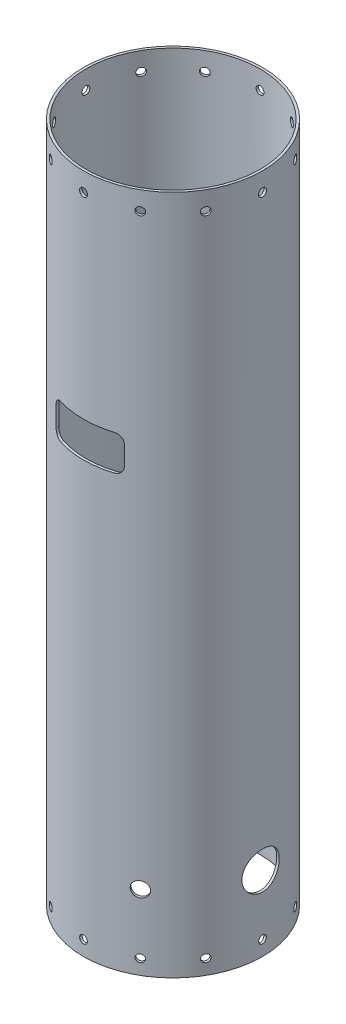
from build123d import *

# Parameters (mm, degrees)
SKETCH_BODY_TUBE_W           = 2.0828
SKETCH_BODY_TUBE_H           = 579.0946
F_1_4_CLEARANCE_HOLE1_REACH  = 605.641
F_1_4_CLEARANCE_HOLE1_BORE_R = 3.3782
CIRPATTERN1_COUNT            = 12
F_1_4_CLEARANCE_HOLE2_REACH  = 593.469
F_1_4_CLEARANCE_HOLE2_BORE_R = 3.2639
CIRPATTERN2_COUNT            = 12
SKETCH5_R                    = 4
SCREW_SWITCH_HOLES_DEPTH     = 590.036022579
SKETCH7_R                    = 12.7
UMBILICAL_HOLE_DEPTH         = 590.036022579
SKETCH8_R                    = 15.875
CONDUIT_HOLE_DEPTH           = 590.036022579
CUT_EXTRUDE5_DEPTH           = 590.036022579
CUT_EXTRUDE7_REACH           = 609.152
CUT_EXTRUDE7_END_RADIUS      = 74.1172
SKETCH12_R                   = 6.35


with BuildPart() as part:
    # Sketch - Body Tube → Revolve - Body Tube (revolve)
    with BuildSketch(Plane.XY, mode=Mode.PRIVATE) as revolve_body_tube_sk:
        with Locations((-75.1586, 289.5473)):
            Rectangle(SKETCH_BODY_TUBE_W, SKETCH_BODY_TUBE_H)
    revolve(revolve_body_tube_sk.sketch.rotate(Axis((0, 0, 0), (0, 1, 0)), 270), axis=Axis((0, 0, 0), (0, 1, 0)))

    # 1_4 Clearance Hole1 bore → 1_4 Clearance Hole1 (cut, up to next)
    with BuildSketch(Plane.XY.offset(76.2), mode=Mode.PRIVATE) as f_1_4_clearance_hole1_sk1:
        with Locations((0, 563.245)):
            Circle(F_1_4_CLEARANCE_HOLE1_BORE_R)
    f_1_4_clearance_hole1_tool1 = extrude(f_1_4_clearance_hole1_sk1.sketch, amount=-F_1_4_CLEARANCE_HOLE1_REACH, mode=Mode.PRIVATE) & part.part
    f_1_4_clearance_hole1 = f_1_4_clearance_hole1_tool1.solids().sort_by_distance((0, 563.245, 76.2))[0]
    add(f_1_4_clearance_hole1, mode=Mode.SUBTRACT)

    # CirPattern1: 1_4 Clearance Hole1 ×12 about axis
    cirpattern1_axis = Axis((0, 0, 0), (0, -1, 0))
    for i in range(1, CIRPATTERN1_COUNT):
        add(f_1_4_clearance_hole1.rotate(cirpattern1_axis, i * 360 / CIRPATTERN1_COUNT), mode=Mode.SUBTRACT)

    # 1_4 Clearance Hole2 bore (on position points) → 1_4 Clearance Hole2 (cut, up to next)
    with BuildSketch(Plane(origin=(0, 12.7, 76.2), x_dir=(1, 0, 0), z_dir=(0, 0, 1)), mode=Mode.PRIVATE) as f_1_4_clearance_hole2_sk1:
        Circle(F_1_4_CLEARANCE_HOLE2_BORE_R)
    f_1_4_clearance_hole2_tool1 = extrude(f_1_4_clearance_hole2_sk1.sketch, amount=-F_1_4_CLEARANCE_HOLE2_REACH, mode=Mode.PRIVATE) & part.part
    f_1_4_clearance_hole2 = f_1_4_clearance_hole2_tool1.solids().sort_by_distance((0, 12.7, 76.2))[0]
    add(f_1_4_clearance_hole2, mode=Mode.SUBTRACT)

    # CirPattern2: 1_4 Clearance Hole2 ×12 about axis
    cirpattern2_axis = Axis((0, 55, 0), (0, -1, 0))
    for i in range(1, CIRPATTERN2_COUNT):
        add(f_1_4_clearance_hole2.rotate(cirpattern2_axis, i * 360 / CIRPATTERN2_COUNT), mode=Mode.SUBTRACT)

    # Sketch5 → Screw Switch Holes (cut, through all)
    with BuildSketch(Plane.XY):
        with Locations((-17.3115, 371.770469026)):
            Circle(SKETCH5_R)
        with Locations((-5.7705, 371.770469026)):
            Circle(SKETCH5_R)
        with Locations((5.7705, 371.770469026)):
            Circle(SKETCH5_R)
        with Locations((17.3115, 371.770469026)):
            Circle(SKETCH5_R)
    extrude(amount=-SCREW_SWITCH_HOLES_DEPTH, mode=Mode.SUBTRACT)

    # Sketch7 → Umbilical Hole (cut, through all)
    with BuildSketch(Plane.XY):
        with Locations(Location((0, 86.0552, 0), (0, 0, 90))):
            Circle(SKETCH7_R)
    extrude(amount=-UMBILICAL_HOLE_DEPTH, mode=Mode.SUBTRACT)

    # Sketch8 → Conduit Hole (cut, through all)
    with BuildSketch(Plane(origin=(0, 0, 0), x_dir=(0, 0, -1), z_dir=(1, 0, 0))):
        with Locations(Location((0, 63.5, 0), (0, 0, 180))):
            Circle(SKETCH8_R)
    extrude(amount=CONDUIT_HOLE_DEPTH, mode=Mode.SUBTRACT)

    # Sketch9 → Cut-Extrude5 (cut, through all)
    with BuildSketch(Plane.XY):
        with BuildLine():
            Line((22.65, 366), (-22.65, 366))
            ThreePointArc((-22.65, 366), (-27.140128061, 367.859871939), (-29, 372.35))
            Line((-29, 372.35), (-29, 389.65))
            ThreePointArc((-29, 389.65), (-27.140128061, 394.140128061), (-22.65, 396))
            Line((-22.65, 396), (22.65, 396))
            ThreePointArc((22.65, 396), (27.140128061, 394.140128061), (29, 389.65))
            Line((29, 389.65), (29, 372.35))
            ThreePointArc((29, 372.35), (27.140128061, 367.859871939), (22.65, 366))
        make_face()
    extrude(amount=CUT_EXTRUDE5_DEPTH, mode=Mode.SUBTRACT)

    # Cut-Extrude7: up to this cylinder (the profile starts outside it)
    cut_extrude7_end = Plane(origin=(0, 63.5, 0), z_dir=(0, -1, 0)) * Cylinder(CUT_EXTRUDE7_END_RADIUS, 1367.5384, mode=Mode.PRIVATE)
    # Sketch12 → Cut-Extrude7 (cut, up to the surface)
    with BuildSketch(Plane(origin=(38.1, 0, 65.991135768), x_dir=(0.8660254037844378, 0, -0.5000000000000017), z_dir=(0.5000000000000016, 0, 0.8660254037844377)), mode=Mode.PRIVATE) as cut_extrude7_sk1:
        with Locations((0, 63.5)):
            Circle(SKETCH12_R)
    cut_extrude7_tool1 = extrude(cut_extrude7_sk1.sketch, amount=-CUT_EXTRUDE7_REACH, mode=Mode.PRIVATE) - cut_extrude7_end
    add(cut_extrude7_tool1.solids().sort_by_distance((38.1, 63.5, 65.991136))[0], mode=Mode.SUBTRACT)


solid = part.part
